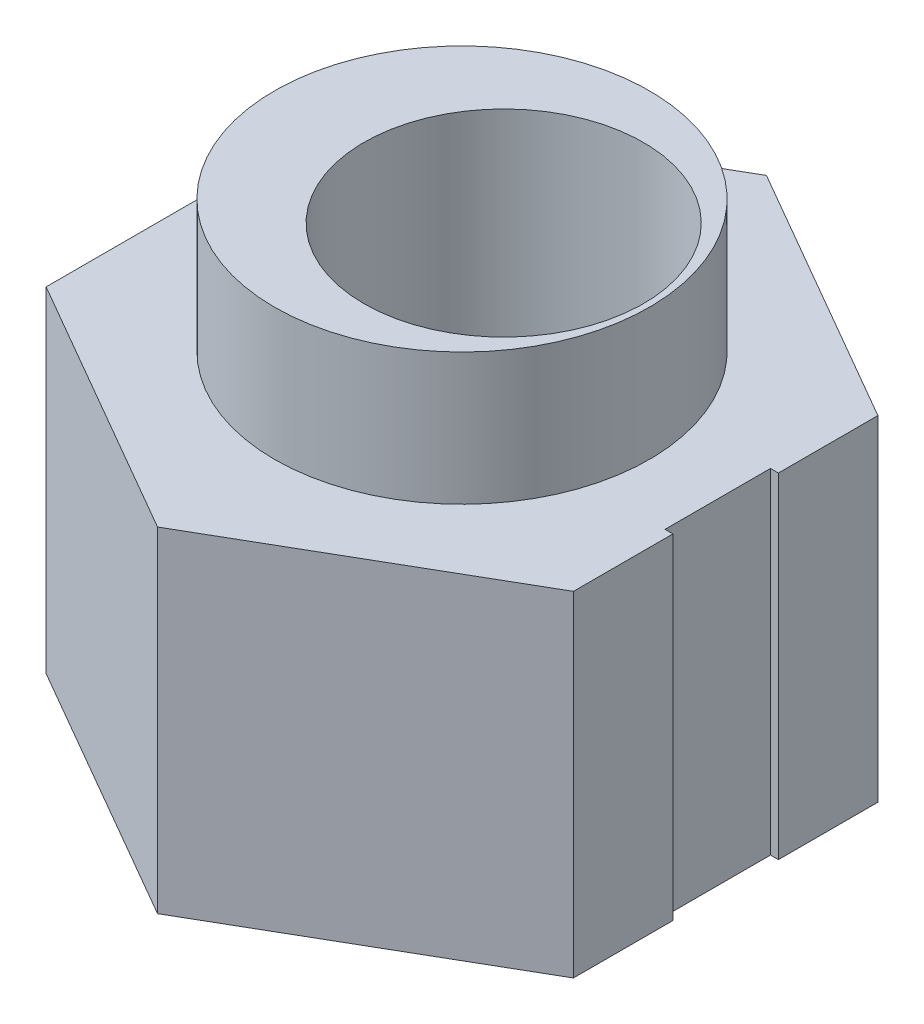
from build123d import *

# Parameters (mm, degrees)
SKETCH1_R           = 2.65
BOSS_EXTRUDE1_DEPTH = 6.35
SKETCH2_R           = 3.555
SKETCH2_R_2         = 2.65
BOSS_EXTRUDE2_DEPTH = 2.5


with BuildPart() as part:
    # Sketch1 → Boss-Extrude1 (new body)
    with BuildSketch(Plane(origin=(0, 0, 0), x_dir=(1, 0, 0), z_dir=(0, 1, 0))):
        Polygon((4.21, 2.886751346), (-0.79, 5.773502692), (-5.79, 2.886751346), (-5.79, -2.886751346), (-0.79, -5.773502692), (4.21, -2.886751346), (4.21, -1), (4.06, -1), (4.06, 1), (4.21, 1), align=None)
        Circle(SKETCH1_R, mode=Mode.SUBTRACT)
    extrude(amount=BOSS_EXTRUDE1_DEPTH)

    # Sketch2 → Boss-Extrude2 (add)
    with BuildSketch(Plane(origin=(0, 6.35, 0), x_dir=(1, 0, 0), z_dir=(0, 1, 0))):
        with Locations((-0.79, 0)):
            Circle(SKETCH2_R)
        Circle(SKETCH2_R_2, mode=Mode.SUBTRACT)
    extrude(amount=BOSS_EXTRUDE2_DEPTH)


solid = part.part
